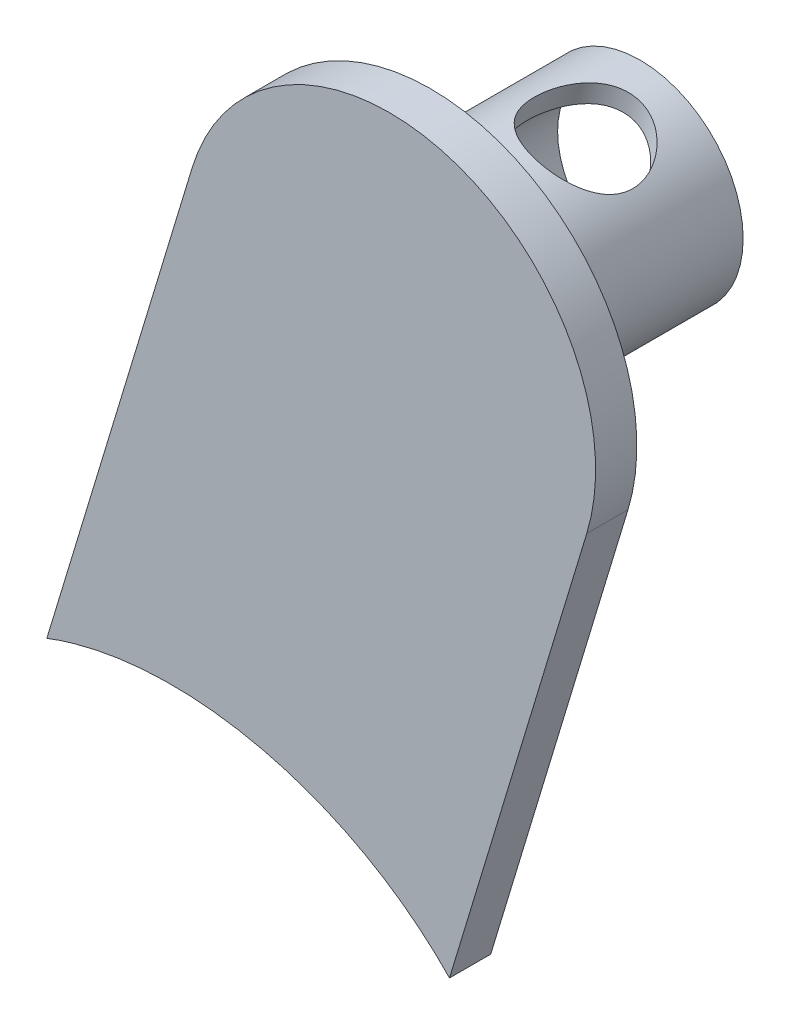
from build123d import *

# Parameters (mm, degrees)
DODANIE_WYCI_GNI_CIE1_DEPTH = 2
SZKIC8_R                    = 5
SZKIC8_R_2                  = 4
EXTRUDE_THIN1_DEPTH         = 10
SKETCH1_R                   = 2.5
CUT_EXTRUDE1_DEPTH          = 20


with BuildPart() as part:
    # Szkic7 → Dodanie-wyciągnięcie1 (new body)
    with BuildSketch(Plane(origin=(0, 0, 617.999346089), x_dir=(-1, 0, 0), z_dir=(0, 0, -1))):
        with BuildLine():
            Line((-1236.2588409, -248.22109889), (-1242.917839996, -226.217062929))
            ThreePointArc((-1242.917839996, -226.217062929), (-1236.243055057, -213.749214437), (-1223.775206565, -220.423999377))
            Line((-1223.775206565, -220.423999377), (-1216.726590952, -243.715486458))
            add(Edge.make_bspline(
                [(-1216.726590952, -243.715486458), (-1223.443292113, -241.147709702), (-1231.151179112, -242.879902365), (-1236.2588409, -248.22109889)],
                knots=[0.154038794, 0.154038794, 0.154038794, 0.154038794, 0.334986093, 0.334986093, 0.334986093, 0.334986093], degree=3, weights=[0.573668424, 0.481060845, 0.475765067, 0.557781088]))
        make_face()
    extrude(amount=DODANIE_WYCI_GNI_CIE1_DEPTH)

    # Szkic8 → Extrude-Thin1 (add)
    with BuildSketch(Plane(origin=(0, 0, 615.999346089), x_dir=(-1, 0, 0), z_dir=(0, 0, -1))):
        with Locations((-1233.504191335, -222.034079566)):
            Circle(SZKIC8_R)
        with Locations((-1233.504191335, -222.034079566)):
            Circle(SZKIC8_R_2, mode=Mode.SUBTRACT)
    extrude(amount=EXTRUDE_THIN1_DEPTH)

    # Sketch1 → Cut-Extrude1 (cut)
    with BuildSketch(Plane(origin=(43.382097596, 143.352059634, 0), x_dir=(0.9571316715628467, -0.28965317759574266, 0), z_dir=(0.28965317759574266, 0.9571316715628467, 0))):
        with Locations((1244.938805213, -609.999346089)):
            Circle(SKETCH1_R)
    extrude(amount=-CUT_EXTRUDE1_DEPTH, mode=Mode.SUBTRACT)


solid = part.part
